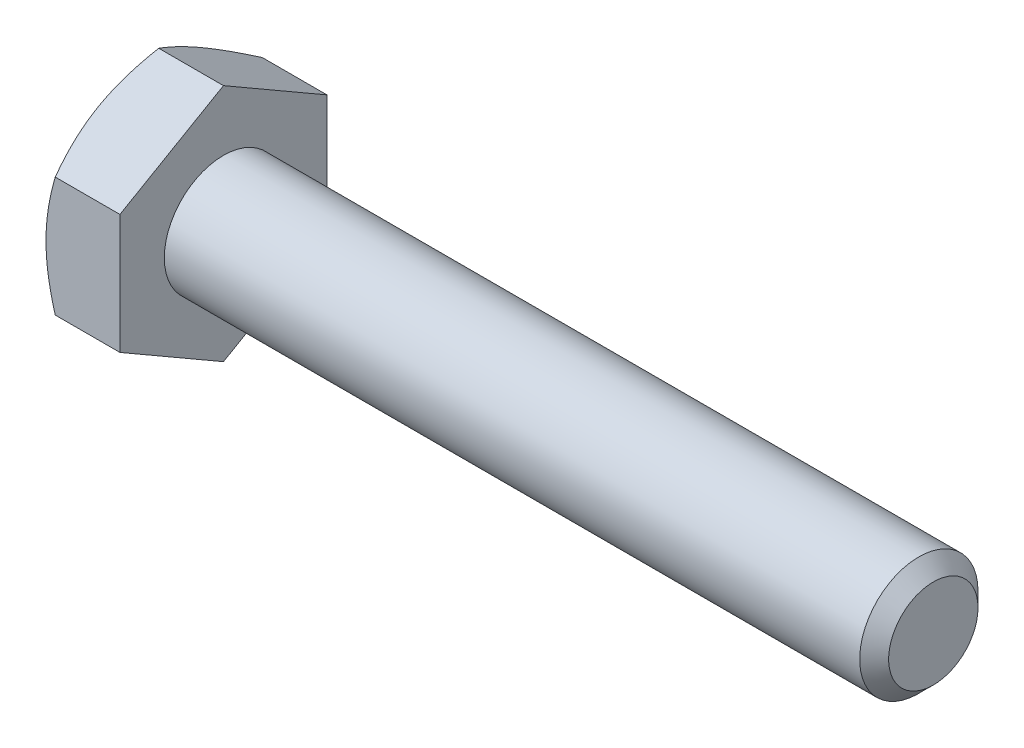
from build123d import *

# Parameters (mm, degrees)
SKETCH5_R           = 3.175
BOSS_EXTRUDE3_DEPTH = 38.1
CHAMFER1_SIZE       = 0.77724
BOSS_EXTRUDE4_DEPTH = 3.96875
SKETCH8_OUTSIDE_W   = 171.38
SKETCH8_OUTSIDE_H   = 173.1
SKETCH8_OUTSIDE_R   = 5.55625
CUT_EXTRUDE3_DEPTH  = 43.06875
CUT_EXTRUDE3_TAPER  = 60
CUT_EXTRUDE4_DEPTH  = 0.254
CIRPATTERN1_COUNT   = 3


with BuildPart() as part:
    # Sketch5 → Boss-Extrude3 (new body)
    with BuildSketch(Plane(origin=(21.034375, 0, 0), x_dir=(0, 0, -1), z_dir=(1, 0, 0))):
        Circle(SKETCH5_R)
    extrude(amount=-BOSS_EXTRUDE3_DEPTH)

    # Chamfer1
    chamfer1_edges = [part.edges().sort_by_distance(p)[0] for p in [
        (21.034375, 0, 3.175),
    ]]
    chamfer(chamfer1_edges, length=CHAMFER1_SIZE)

    # Sketch6 → Boss-Extrude4 (add)
    with BuildSketch(Plane.ZY.offset(17.065625)):
        Polygon((5.55625, 3.207902433), (0, 6.415804866), (-5.55625, 3.207902433), (-5.55625, -3.207902433), (0, -6.415804866), (5.55625, -3.207902433), align=None)
    extrude(amount=BOSS_EXTRUDE4_DEPTH)

    # Sketch8 outside → Cut-Extrude3 (cut, through all)
    with BuildSketch(Plane.ZY.offset(21.034375)):
        Rectangle(SKETCH8_OUTSIDE_W, SKETCH8_OUTSIDE_H)
        Circle(SKETCH8_OUTSIDE_R, mode=Mode.SUBTRACT)
    extrude(amount=-CUT_EXTRUDE3_DEPTH, taper=CUT_EXTRUDE3_TAPER, mode=Mode.SUBTRACT)

    # Sketch12 → Cut-Extrude4 (cut)
    with BuildSketch(Plane.ZY.offset(21.034375)):
        with BuildLine():
            Line((0.1666875, 4.2783125), (0.1666875, 2.3891875))
            ThreePointArc((0.1666875, 2.3891875), (0, 2.2225), (-0.1666875, 2.3891875))
            Line((-0.1666875, 2.3891875), (-0.1666875, 4.2783125))
            ThreePointArc((-0.1666875, 4.2783125), (0, 4.445), (0.1666875, 4.2783125))
        make_face()
    cut_extrude4 = extrude(amount=-CUT_EXTRUDE4_DEPTH, mode=Mode.SUBTRACT)

    # CirPattern1: Cut-Extrude4 ×3 about axis
    cirpattern1_axis = Axis((0, 0, 0), (1, 0, 0))
    for i in range(1, CIRPATTERN1_COUNT):
        add(cut_extrude4.rotate(cirpattern1_axis, i * 360 / CIRPATTERN1_COUNT), mode=Mode.SUBTRACT)


solid = part.part
